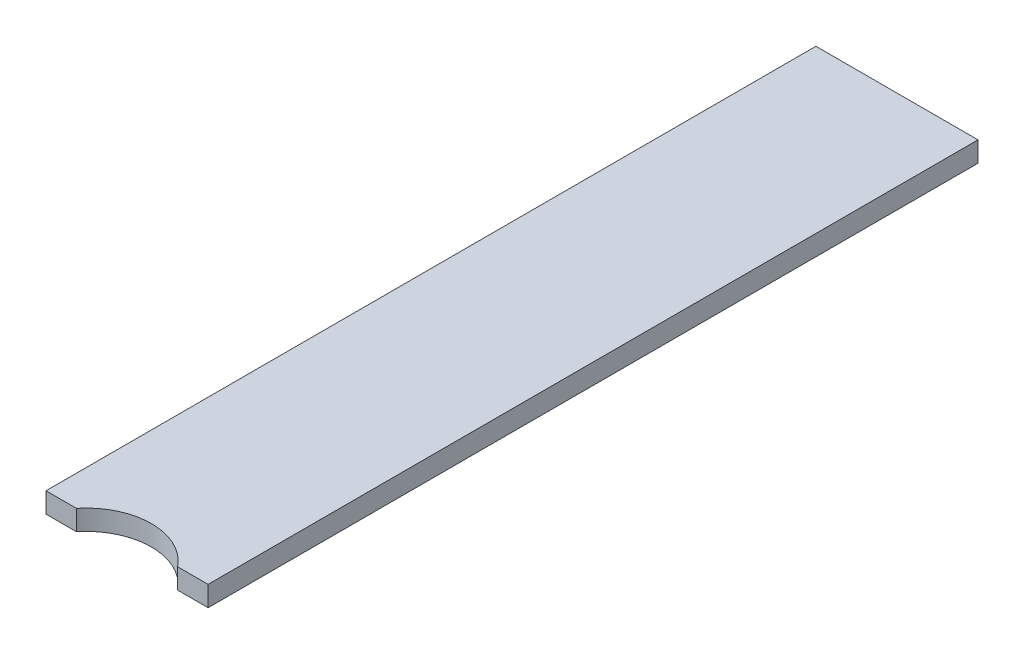
from build123d import *

# Parameters (mm, degrees)
SKETCH_1_W          = 40
SKETCH_1_H          = 5
EXTRUDE_1_DEPTH     = 200
SKETCH_2_R          = 16
CUT_EXTRUDE_1_DEPTH = 6
SKETCH_3_W          = 40
SKETCH_3_H          = 10
CUT_EXTRUDE_2_DEPTH = 6


with BuildPart() as part:
    # Эскиз1 → Бобышка-Вытянуть1 (new body)
    with BuildSketch(Plane.XY):
        with Locations((20, -2.5)):
            Rectangle(SKETCH_1_W, SKETCH_1_H)
    extrude(amount=EXTRUDE_1_DEPTH)

    # Эскиз2 → Вырез-Вытянуть1 (cut, through all)
    with BuildSketch(Plane(origin=(0, 0, 0), x_dir=(1, 0, 0), z_dir=(0, 1, 0))):
        with Locations((20, -200)):
            Circle(SKETCH_2_R)
    extrude(amount=-CUT_EXTRUDE_1_DEPTH, mode=Mode.SUBTRACT)

    # Эскиз3 → Вырез-Вытянуть2 (cut, through all)
    with BuildSketch(Plane.XZ.offset(5)):
        with Locations((20, 195)):
            Rectangle(SKETCH_3_W, SKETCH_3_H)
    extrude(amount=-CUT_EXTRUDE_2_DEPTH, mode=Mode.SUBTRACT)


solid = part.part
